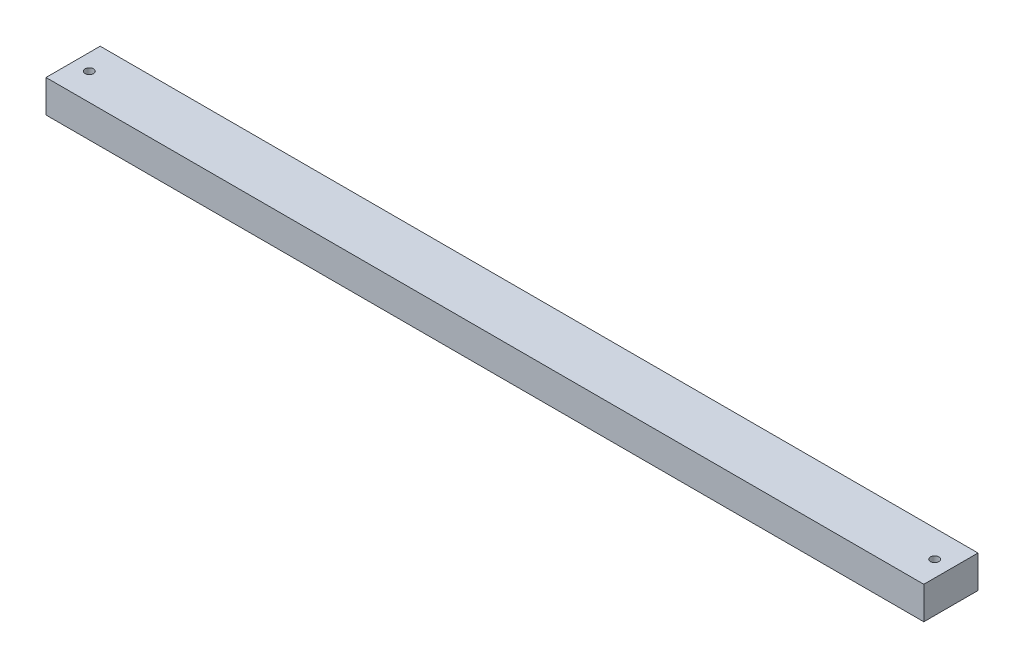
from build123d import *

# Parameters (mm, degrees)
SKETCH1_W           = 324
SKETCH1_H           = 20
BOSS_EXTRUDE1_DEPTH = 12
SKETCH2_R           = 1.55
CUT_EXTRUDE1_DEPTH  = 13


with BuildPart() as part:
    # Sketch1 → Boss-Extrude1 (new body)
    with BuildSketch(Plane(origin=(0, 0, 0), x_dir=(1, 0, 0), z_dir=(0, 1, 0))):
        Rectangle(SKETCH1_W, SKETCH1_H)
    extrude(amount=BOSS_EXTRUDE1_DEPTH)

    # Sketch2 → Cut-Extrude1 (cut, through all)
    with BuildSketch(Plane(origin=(0, 12, 0), x_dir=(1, 0, 0), z_dir=(0, 1, 0))):
        with Locations(Location((-156, 0, 0), (0, 0, 270))):  # turned: the seam where the file's is
            Circle(SKETCH2_R)
        with Locations(Location((156, 0, 0), (0, 0, 270))):  # turned: the seam where the file's is
            Circle(SKETCH2_R)
    extrude(amount=-CUT_EXTRUDE1_DEPTH, mode=Mode.SUBTRACT)


solid = part.part
